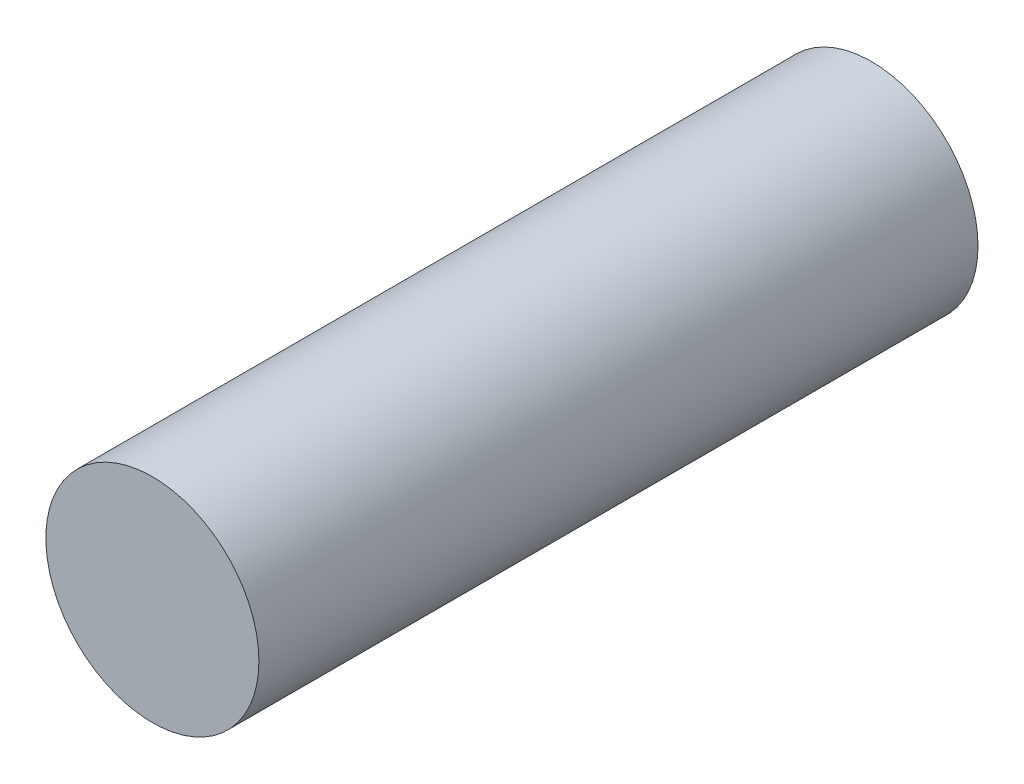
from build123d import *

# Parameters (mm, degrees)
SKETCH2_R           = 40
BOSS_EXTRUDE1_DEPTH = 270


with BuildPart() as part:
    # Sketch2 → Boss-Extrude1 (new body)
    with BuildSketch(Plane.XY):
        Circle(SKETCH2_R)
    extrude(amount=BOSS_EXTRUDE1_DEPTH)


solid = part.part
